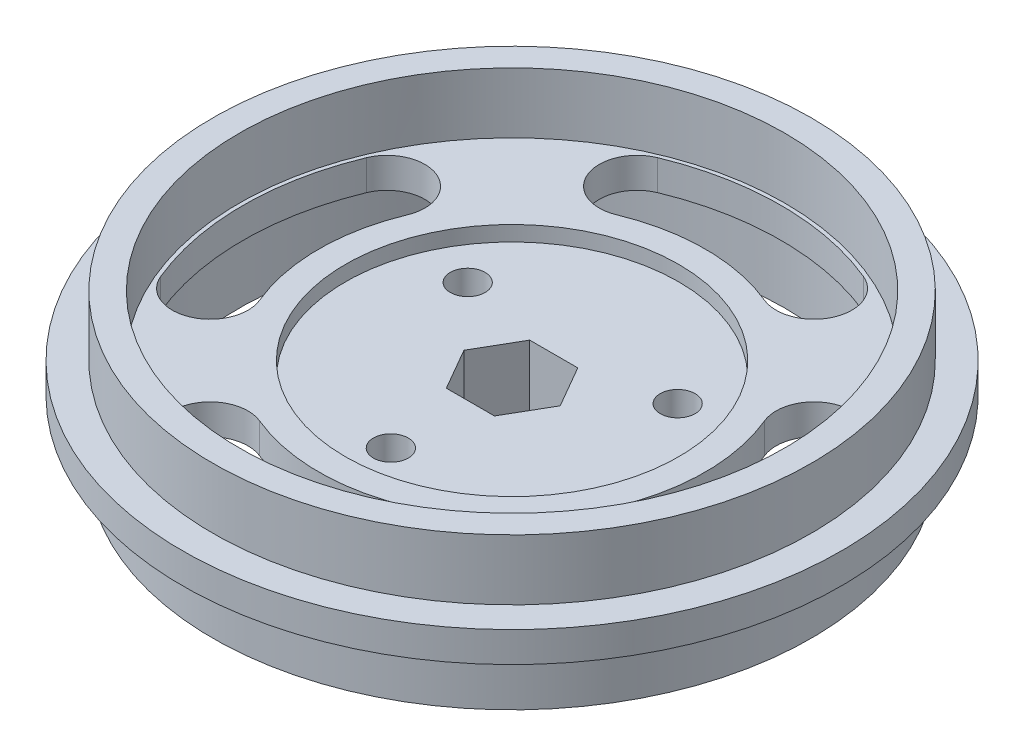
from build123d import *

# Parameters (mm, degrees)
SKETCH3_R           = 18
BOSS_EXTRUDE1_DEPTH = 1
SKETCH4_R           = 11
CUT_EXTRUDE1_DEPTH  = 1
SKETCH5_R           = 1.15
CUT_EXTRUDE2_DEPTH  = 6
SKETCH6_R           = 11
SKETCH6_R_2         = 1.15
BOSS_EXTRUDE2_DEPTH = 3
SKETCH9_R           = 11
SKETCH9_R_2         = 2.15
BOSS_EXTRUDE3_DEPTH = 2


with BuildPart() as part:
    # Sketch1 → Revolve1 (revolve)
    with BuildSketch(Plane.XY):
        Polygon((18, 5), (18, -5), (19.75, -5), (19.75, -1), (21.75, -1), (21.75, 1), (19.75, 1), (19.75, 5), align=None)
    revolve(axis=Axis((0, 0, 0), (0, 1, 0)))

    # Sketch3 → Boss-Extrude1 (add, symmetric)
    with BuildSketch(Plane(origin=(0, 0, 0), x_dir=(1, 0, 0), z_dir=(0, 1, 0))):
        Circle(SKETCH3_R)
        with BuildLine():
            ThreePointArc((-6.792630924, -16.398861702), (-8.145621175, -13.13245429), (-4.879213763, -11.77946404))
            ThreePointArc((-4.879213763, -11.77946404), (0, -12.75), (4.879213763, -11.77946404))
            ThreePointArc((4.879213763, -11.77946404), (8.145621175, -13.13245429), (6.792630924, -16.398861702))
            ThreePointArc((6.792630924, -16.398861702), (0, -17.75), (-6.792630924, -16.398861702))
        make_face(mode=Mode.SUBTRACT)
        with BuildLine():
            ThreePointArc((16.398861702, -6.792630924), (13.13245429, -8.145621175), (11.77946404, -4.879213763))
            ThreePointArc((11.77946404, -4.879213763), (12.75, 0), (11.77946404, 4.879213763))
            ThreePointArc((11.77946404, 4.879213763), (13.13245429, 8.145621175), (16.398861702, 6.792630924))
            ThreePointArc((16.398861702, 6.792630924), (17.75, 0), (16.398861702, -6.792630924))
        make_face(mode=Mode.SUBTRACT)
        with BuildLine():
            ThreePointArc((-16.398861702, 6.792630924), (-13.13245429, 8.145621175), (-11.77946404, 4.879213763))
            ThreePointArc((-11.77946404, 4.879213763), (-12.75, 0), (-11.77946404, -4.879213763))
            ThreePointArc((-11.77946404, -4.879213763), (-13.13245429, -8.145621175), (-16.398861702, -6.792630924))
            ThreePointArc((-16.398861702, -6.792630924), (-17.75, 0), (-16.398861702, 6.792630924))
        make_face(mode=Mode.SUBTRACT)
        with BuildLine():
            ThreePointArc((-4.879213763, 11.77946404), (-8.145621175, 13.13245429), (-6.792630924, 16.398861702))
            ThreePointArc((-6.792630924, 16.398861702), (0, 17.75), (6.792630924, 16.398861702))
            ThreePointArc((6.792630924, 16.398861702), (8.145621175, 13.13245429), (4.879213763, 11.77946404))
            ThreePointArc((4.879213763, 11.77946404), (0, 12.75), (-4.879213763, 11.77946404))
        make_face(mode=Mode.SUBTRACT)
    extrude(amount=BOSS_EXTRUDE1_DEPTH, both=True)

    # Sketch4 → Cut-Extrude1 (cut)
    with BuildSketch(Plane(origin=(0, 1, 0), x_dir=(1, 0, 0), z_dir=(0, 1, 0))):
        Circle(SKETCH4_R)
    extrude(amount=-CUT_EXTRUDE1_DEPTH, mode=Mode.SUBTRACT)

    # Sketch5 → Cut-Extrude2 (cut, through all)
    with BuildSketch(Plane(origin=(0, 0, 0), x_dir=(1, 0, 0), z_dir=(0, 1, 0))):
        with Locations((0, -8)):
            Circle(SKETCH5_R)
        with Locations((-6.92820323, 4)):
            Circle(SKETCH5_R)
        with Locations((6.92820323, 4)):
            Circle(SKETCH5_R)
        Polygon((3.175426481, 0), (1.58771324, 2.75), (-1.58771324, 2.75), (-3.175426481, 0), (-1.58771324, -2.75), (1.58771324, -2.75), align=None)
    extrude(amount=-CUT_EXTRUDE2_DEPTH, mode=Mode.SUBTRACT)

    # Sketch6 → Boss-Extrude2 (add)
    with BuildSketch(Plane.XZ.offset(1)):
        Circle(SKETCH6_R)
        with Locations((-6.92820323, -4)):
            Circle(SKETCH6_R_2, mode=Mode.SUBTRACT)
        with Locations((6.92820323, -4)):
            Circle(SKETCH6_R_2, mode=Mode.SUBTRACT)
        with Locations((0, 8)):
            Circle(SKETCH6_R_2, mode=Mode.SUBTRACT)
        Polygon((3.175426481, 0), (1.58771324, -2.75), (-1.58771324, -2.75), (-3.175426481, 0), (-1.58771324, 2.75), (1.58771324, 2.75), align=None, mode=Mode.SUBTRACT)
    extrude(amount=BOSS_EXTRUDE2_DEPTH)

    # Sketch9 → Boss-Extrude3 (add)
    with BuildSketch(Plane.XZ.offset(4)):
        Circle(SKETCH9_R)
        with Locations((0, 8)):
            Circle(SKETCH9_R_2, mode=Mode.SUBTRACT)
        with Locations((-6.92820323, -4)):
            Circle(SKETCH9_R_2, mode=Mode.SUBTRACT)
        with Locations((6.92820323, -4)):
            Circle(SKETCH9_R_2, mode=Mode.SUBTRACT)
        Polygon((-1.58771324, -2.75), (1.58771324, -2.75), (3.175426481, 0), (1.58771324, 2.75), (-1.58771324, 2.75), (-3.175426481, 0), align=None, mode=Mode.SUBTRACT)
    extrude(amount=BOSS_EXTRUDE3_DEPTH)


solid = part.part
